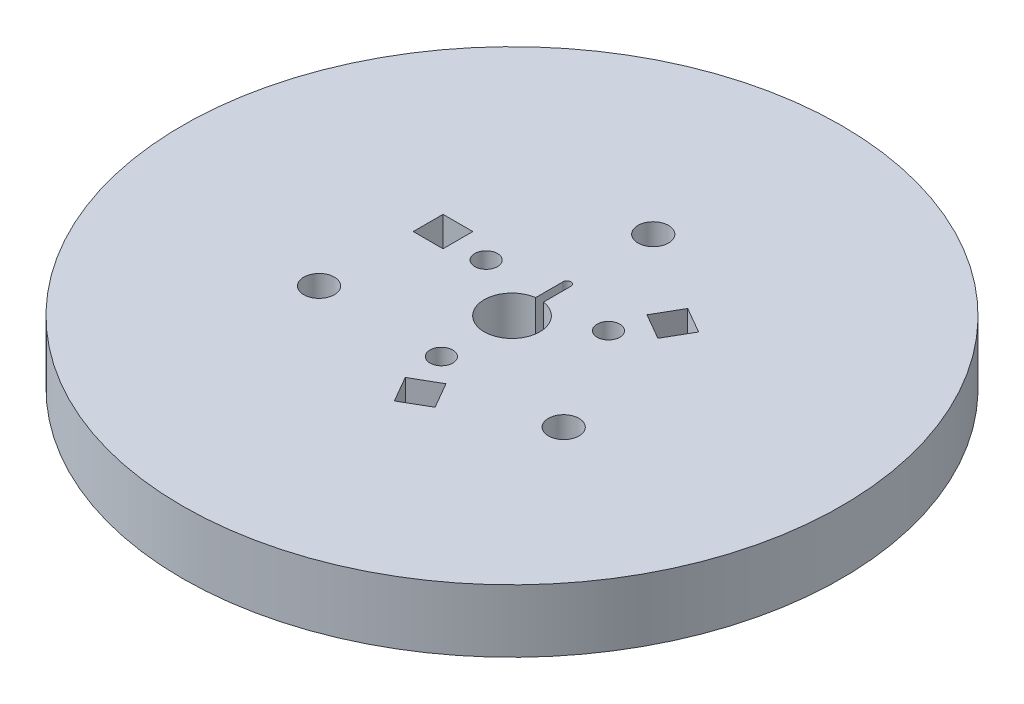
from build123d import *

# Parameters (mm, degrees)
SKETCH1_R           = 42
SKETCH1_R_2         = 1.95
SKETCH1_R_3         = 3.55
SKETCH1_R_4         = 1.45
BOSS_EXTRUDE1_DEPTH = 8
CUT_EXTRUDE2_DEPTH  = 10
SKETCH4_W           = 3.8
SKETCH4_H           = 3.8
CUT_EXTRUDE3_DEPTH  = 35
SKETCH5_R           = 12
SKETCH5_R_2         = 1.45
BOSS_EXTRUDE2_DEPTH = 3


with BuildPart() as part:
    # Sketch1 → Boss-Extrude1 (new body)
    with BuildSketch(Plane(origin=(0, 0, 0), x_dir=(1, 0, 0), z_dir=(0, 1, 0))):
        Circle(SKETCH1_R)
        with Locations((0, 18)):
            Circle(SKETCH1_R_2, mode=Mode.SUBTRACT)
        with Locations((15.588457268, -9)):
            Circle(SKETCH1_R_2, mode=Mode.SUBTRACT)
        with Locations((-15.588457268, -9)):
            Circle(SKETCH1_R_2, mode=Mode.SUBTRACT)
        Circle(SKETCH1_R_3, mode=Mode.SUBTRACT)
        with Locations((7.794228634, 4.5)):
            Circle(SKETCH1_R_4, mode=Mode.SUBTRACT)
        with Locations((0, -9)):
            Circle(SKETCH1_R_4, mode=Mode.SUBTRACT)
        with Locations((-7.794228634, 4.5)):
            Circle(SKETCH1_R_4, mode=Mode.SUBTRACT)
    extrude(amount=BOSS_EXTRUDE1_DEPTH)

    # Sketch3 → Cut-Extrude2 (cut)
    with BuildSketch(Plane(origin=(0, 8, 0), x_dir=(1, 0, 0), z_dir=(0, 1, 0))):
        with BuildLine():
            Line((0.5, 7), (0.5, 0))
            ThreePointArc((0.5, 0), (0, -0.5), (-0.5, 0))
            Line((-0.5, 0), (-0.5, 7))
            ThreePointArc((-0.5, 7), (0, 7.5), (0.5, 7))
        make_face()
    extrude(amount=-CUT_EXTRUDE2_DEPTH, mode=Mode.SUBTRACT)

    # Sketch4 → Cut-Extrude3 (cut)
    with BuildSketch(Plane(origin=(0, 8, 0), x_dir=(1, 0, 0), z_dir=(0, 1, 0))):
        Polygon((1.905255888, -16.9), (5.196152423, -15), (3.296152423, -11.709103466), (0.005255888, -13.609103466), align=None)
        with Locations((-13.688457268, 4.9)):
            Rectangle(SKETCH4_W, SKETCH4_H)
        Polygon((13.68320138, 10.1), (10.392304845, 12), (8.492304845, 8.709103466), (11.78320138, 6.809103466), align=None)
    extrude(amount=-CUT_EXTRUDE3_DEPTH, mode=Mode.SUBTRACT)

    # Sketch5 → Boss-Extrude2 (add)
    with BuildSketch(Plane.XZ):
        Circle(SKETCH5_R)
        with Locations((0, 9)):
            Circle(SKETCH5_R_2, mode=Mode.SUBTRACT)
        with Locations((-7.794228634, -4.5)):
            Circle(SKETCH5_R_2, mode=Mode.SUBTRACT)
        with Locations((7.794228634, -4.5)):
            Circle(SKETCH5_R_2, mode=Mode.SUBTRACT)
        with BuildLine():
            Line((-0.5, -7), (-0.5, -3.514612354))
            ThreePointArc((-0.5, -3.514612354), (0, 3.55), (0.5, -3.514612354))
            Line((0.5, -3.514612354), (0.5, -7))
            ThreePointArc((0.5, -7), (0, -7.5), (-0.5, -7))
        make_face(mode=Mode.SUBTRACT)
    extrude(amount=BOSS_EXTRUDE2_DEPTH)


solid = part.part
